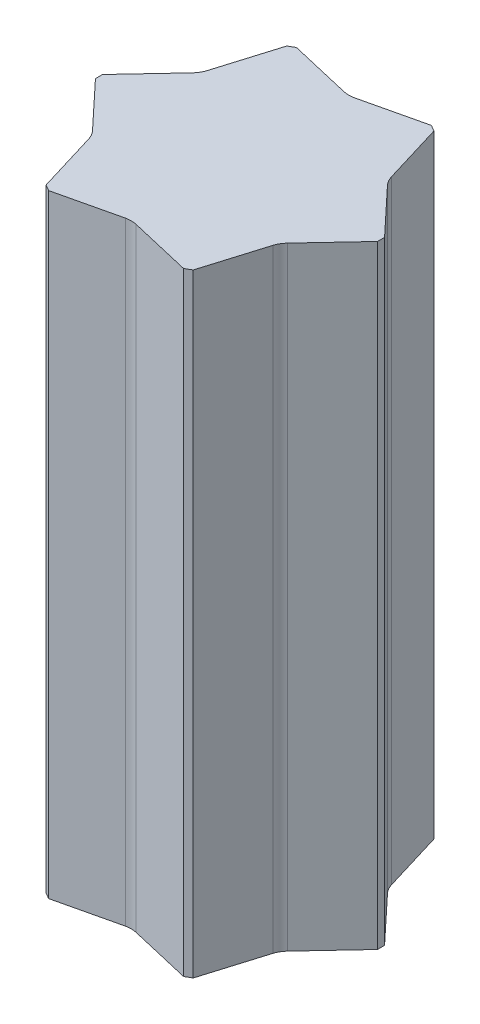
from build123d import *

# Parameters (mm, degrees)
EXTRUDE_1_DEPTH     = 1500
CUT_EXTRUDE_4_DEPTH = 1500


with BuildPart() as part:
    # 草图2 → 凸台-拉伸1 (new body)
    with BuildSketch(Plane(origin=(0, 0, 0), x_dir=(1, 0, 0), z_dir=(0, 1, 0))):
        Polygon((345, 8.660254038), (180, 294.448637287), (165, 303.108891325), (-165, 303.108891325), (-180, 294.448637287), (-345, 8.660254038), (-345, -8.660254038), (-180, -294.448637287), (-165, -303.108891325), (165, -303.108891325), (180, -294.448637287), (345, -8.660254038), align=None)
    extrude(amount=EXTRUDE_1_DEPTH)

    # 草图5 → 切除-拉伸4 (cut)
    with BuildSketch(Plane(origin=(0, 0, 0), x_dir=(1, 0, 0), z_dir=(0, 1, 0))):
        with BuildLine():
            Line((238.21737139, 122.528375301), (345, 8.660254038))
            Line((345, 8.660254038), (379.520233023, 28.590519866))
            Line((379.520233023, 28.590519866), (334.34391274, 178.027059826))
            ThreePointArc((334.34391274, 178.027059826), (329.146090081, 190.032583711), (321.34791274, 200.536792121))
            Line((321.34791274, 200.536792121), (214.969297582, 314.638170659))
            Line((214.969297582, 314.638170659), (180, 294.448637287))
            Line((180, 294.448637287), (225.22137139, 145.038107596))
            ThreePointArc((225.22137139, 145.038107596), (230.419194049, 133.032583711), (238.21737139, 122.528375301))
        make_face()
        with BuildLine():
            Line((225.22137139, -145.038107596), (180, -294.448637287))
            Line((180, -294.448637287), (214.520233023, -314.378903115))
            Line((214.520233023, -314.378903115), (321.34791274, -200.536792121))
            ThreePointArc((321.34791274, -200.536792121), (329.146090081, -190.032583711), (334.34391274, -178.027059826))
            Line((334.34391274, -178.027059826), (379.969297582, -28.84978741))
            Line((379.969297582, -28.84978741), (345, -8.660254038))
            Line((345, -8.660254038), (238.21737139, -122.528375301))
            ThreePointArc((238.21737139, -122.528375301), (230.419194049, -133.032583711), (225.22137139, -145.038107596))
        make_face()
        with BuildLine():
            Line((12.996, 267.566482896), (165, 303.108891325))
            Line((165, 303.108891325), (165, 342.969422981))
            Line((165, 342.969422981), (12.996, 378.563851946))
            ThreePointArc((12.996, 378.563851946), (0, 380.065167421), (-12.996, 378.563851946))
            Line((-12.996, 378.563851946), (-165, 343.487958069))
            Line((-165, 343.487958069), (-165, 303.108891325))
            Line((-165, 303.108891325), (-12.996, 267.566482896))
            ThreePointArc((-12.996, 267.566482896), (0, 266.065167421), (12.996, 267.566482896))
        make_face()
        with BuildLine():
            Line((-12.996, -267.566482896), (-165, -303.108891325))
            Line((-165, -303.108891325), (-165, -342.969422981))
            Line((-165, -342.969422981), (-12.996, -378.563851946))
            ThreePointArc((-12.996, -378.563851946), (0, -380.065167421), (12.996, -378.563851946))
            Line((12.996, -378.563851946), (165, -343.487958069))
            Line((165, -343.487958069), (165, -303.108891325))
            Line((165, -303.108891325), (12.996, -267.566482896))
            ThreePointArc((12.996, -267.566482896), (0, -266.065167421), (-12.996, -267.566482896))
        make_face()
        with BuildLine():
            Line((-238.21737139, -122.528375301), (-345, -8.660254038))
            Line((-345, -8.660254038), (-379.520233023, -28.590519866))
            Line((-379.520233023, -28.590519866), (-334.34391274, -178.027059826))
            ThreePointArc((-334.34391274, -178.027059826), (-329.146090081, -190.032583711), (-321.34791274, -200.536792121))
            Line((-321.34791274, -200.536792121), (-214.969297582, -314.638170659))
            Line((-214.969297582, -314.638170659), (-180, -294.448637287))
            Line((-180, -294.448637287), (-225.22137139, -145.038107596))
            ThreePointArc((-225.22137139, -145.038107596), (-230.419194049, -133.032583711), (-238.21737139, -122.528375301))
        make_face()
        with BuildLine():
            Line((-225.22137139, 145.038107596), (-180, 294.448637287))
            Line((-180, 294.448637287), (-214.520233023, 314.378903115))
            Line((-214.520233023, 314.378903115), (-321.34791274, 200.536792121))
            ThreePointArc((-321.34791274, 200.536792121), (-329.14609008, 190.032583711), (-334.34391274, 178.027059826))
            Line((-334.34391274, 178.027059826), (-379.969297582, 28.84978741))
            Line((-379.969297582, 28.84978741), (-345, 8.660254038))
            Line((-345, 8.660254038), (-238.21737139, 122.528375301))
            ThreePointArc((-238.21737139, 122.528375301), (-230.419194049, 133.032583711), (-225.22137139, 145.038107596))
        make_face()
    extrude(amount=CUT_EXTRUDE_4_DEPTH, mode=Mode.SUBTRACT)


solid = part.part
